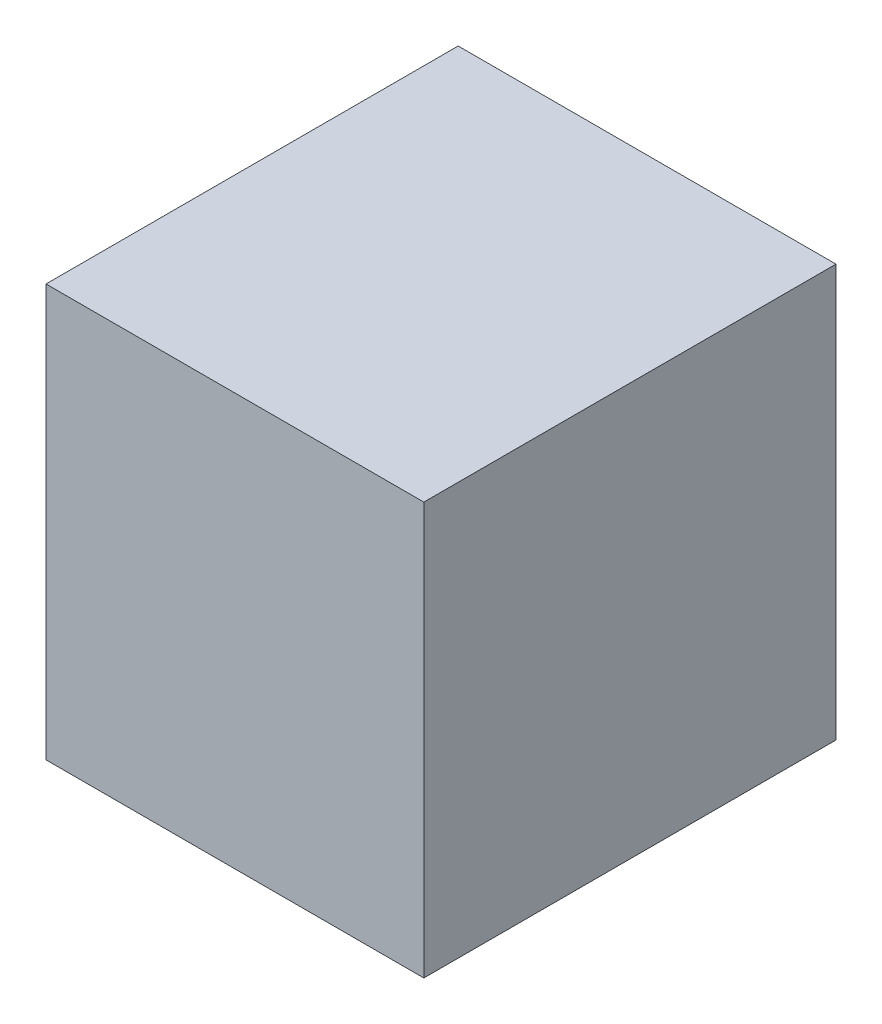
from build123d import *

# Parameters (mm, degrees)
SKETCH1_W           = 550
SKETCH1_H           = 600
BOSS_EXTRUDE1_DEPTH = 600


with BuildPart() as part:
    # Sketch1 → Boss-Extrude1 (new body)
    with BuildSketch(Plane.XY):
        with Locations((-275, 300)):
            Rectangle(SKETCH1_W, SKETCH1_H)
    extrude(amount=BOSS_EXTRUDE1_DEPTH)


solid = part.part
